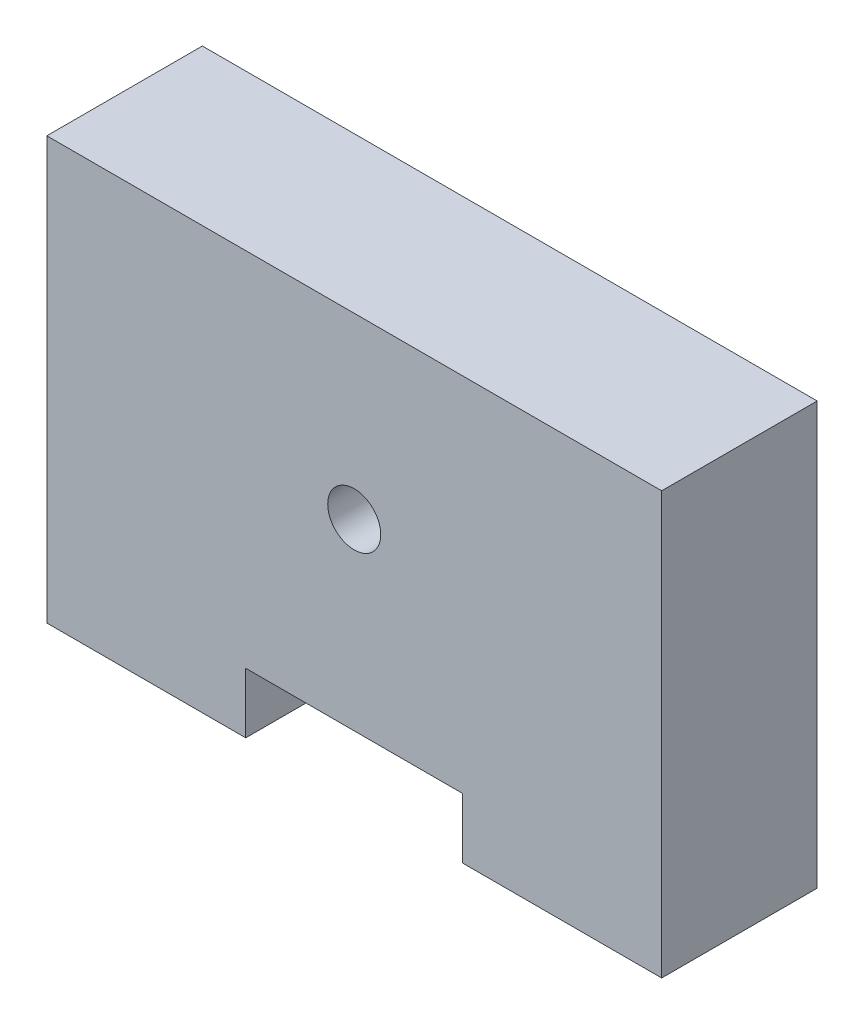
from build123d import *

# Parameters (mm, degrees)
SKETCH2_W                 = 51
SKETCH2_H                 = 12.9
BOSS_EXTRUDE1_DEPTH       = 35
M3X0_5_TAPPED_HOLE1_D     = 2.5
M3X0_5_TAPPED_HOLE1_DEPTH = 16
M3X0_5_TAPPED_HOLE1_TIP   = 0.751075774
SKETCH5_R                 = 2.2
SKETCH5_W                 = 18
SKETCH5_H                 = 5
CUT_EXTRUDE1_DEPTH        = 12.9


with BuildPart() as part:
    # Sketch2 → Boss-Extrude1 (new body)
    with BuildSketch(Plane(origin=(0, 0, 0), x_dir=(1, 0, 0), z_dir=(0, 1, 0))):
        Rectangle(SKETCH2_W, SKETCH2_H)
    extrude(amount=BOSS_EXTRUDE1_DEPTH)

    # M3x0.5 Tapped Hole1
    with Locations(Plane(origin=(0, 0, 0), x_dir=(-1, 0, 0), z_dir=(0, -1, 0))):
        with Locations((-18.75, 0), (18.75, 0)):
            Hole(M3X0_5_TAPPED_HOLE1_D / 2, depth=M3X0_5_TAPPED_HOLE1_DEPTH)
            with Locations((0, 0, -(M3X0_5_TAPPED_HOLE1_DEPTH + M3X0_5_TAPPED_HOLE1_TIP / 2))):  # 118° drill point
                Cone(0, M3X0_5_TAPPED_HOLE1_D / 2, M3X0_5_TAPPED_HOLE1_TIP, mode=Mode.SUBTRACT)

    # Sketch5 → Cut-Extrude1 (cut)
    with BuildSketch(Plane(origin=(0, 0, -6.45), x_dir=(-1, 0, 0), z_dir=(0, 0, -1))):
        with Locations((0, 20.2)):
            Circle(SKETCH5_R)
        with Locations((0, 2.5)):
            Rectangle(SKETCH5_W, SKETCH5_H)
    extrude(amount=-CUT_EXTRUDE1_DEPTH, mode=Mode.SUBTRACT)


solid = part.part
